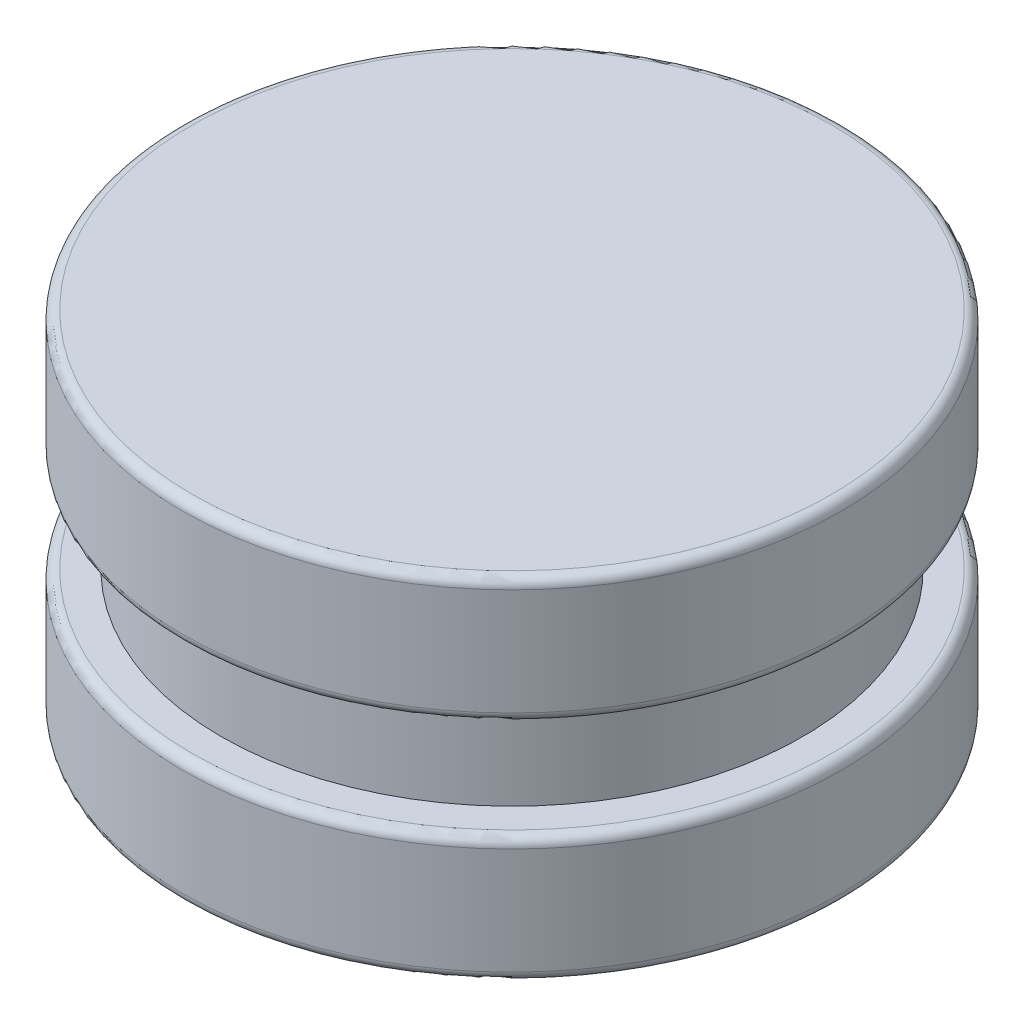
from build123d import *

# Parameters (mm, degrees)
SKETCH1_R           = 34.00044
BOSS_EXTRUDE1_DEPTH = 13
FILLET1_R           = 1
LPATTERN1_COUNT     = 2
LPATTERN1_PITCH     = 23.16
SKETCH2_R           = 30
BOSS_EXTRUDE2_DEPTH = 23.16


with BuildPart() as part:
    # Sketch1 → Boss-Extrude1 (new body)
    with BuildSketch(Plane(origin=(0, 0, 0), x_dir=(1, 0, 0), z_dir=(0, 1, 0))):
        Circle(SKETCH1_R)
    extrude(amount=BOSS_EXTRUDE1_DEPTH)

    # Fillet1
    fillet1_edges = [part.edges().sort_by_distance(p)[0] for p in [
        (-34.00044, 0, 0),
        (-34.00044, 13, 0),
    ]]
    fillet(fillet1_edges, radius=FILLET1_R)


with BuildPart() as lpattern1_1:
    # LPattern1: pattern copy
    add(part.part.moved(Location(Vector(0, 1, 0) * (1 * LPATTERN1_PITCH))))


with BuildPart() as part_1:
    add(part.part)

    add(lpattern1_1.part)  # Boss-Extrude2 merges LPattern1_1
    # Sketch2 → Boss-Extrude2 (add)
    with BuildSketch(Plane(origin=(0, 13, 0), x_dir=(1, 0, 0), z_dir=(0, 1, 0))):
        Circle(SKETCH2_R)
    extrude(amount=BOSS_EXTRUDE2_DEPTH)


solid = part_1.part
